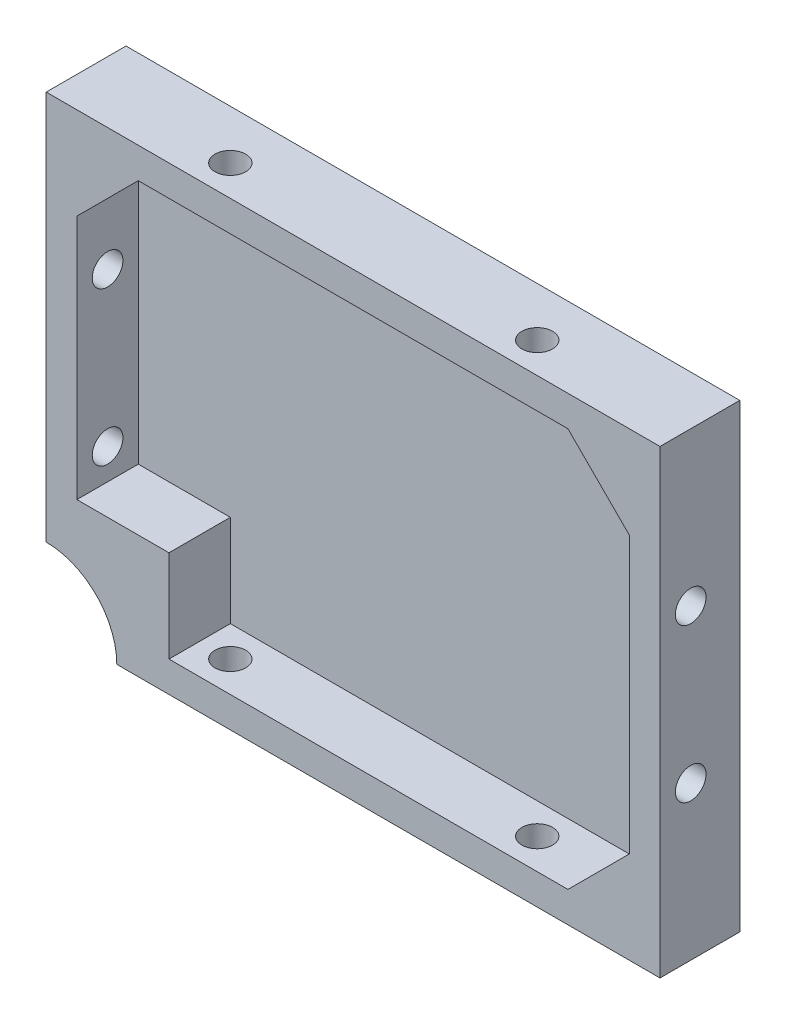
from build123d import *

# Parameters (mm, degrees)
BOSS_EXTRU_1_DEPTH        = 13
COQUE1_T                  = -5
COQUE1_THICKNESS_2_FACE_W = 90
COQUE1_THICKNESS_2_FACE_H = 65
COQUE1_THICKNESS_2_DEPTH  = 2
ENL_V_MAT_EXTRU_1_REACH   = 110.96
ESQUISSE2_R               = 2.5
ENL_V_MAT_EXTRU_2_REACH   = 95.396
ESQUISSE3_R               = 2.5
ESQUISSE4_W               = 15
ESQUISSE4_H               = 15
BOSS_EXTRU_2_DEPTH        = 10
ESQUISSE6_R               = 11.5
ENL_V_MAT_EXTRU_4_DEPTH   = 13


with BuildPart() as part:
    # Esquisse1 → Boss.-Extru.1 (new body)
    with BuildSketch(Plane.XY):
        Polygon((44.118436308, 33.728448276), (54.118436308, 33.728448276), (54.118436308, 23.728448276), (54.118436308, -41.271551724), (-45.881563692, -41.271551724), (-45.881563692, 33.728448276), align=None)
    extrude(amount=BOSS_EXTRU_1_DEPTH)

    # Coque1
    coque1_openings = [part.faces().sort_by_distance(p)[0] for p in [
        (4.118436308, -3.771551724, 13),
    ]]
    offset(amount=COQUE1_T, openings=coque1_openings, kind=Kind.INTERSECTION)

    # Coque1 thickness 2 face (on inner face of the shell) → Coque1 thickness 2 (cut)
    with BuildSketch(Plane(origin=(4.118436308, -3.771551724, 5), x_dir=(-1, 0, 0), z_dir=(0, 0, -1))):
        Rectangle(COQUE1_THICKNESS_2_FACE_W, COQUE1_THICKNESS_2_FACE_H)
    extrude(amount=COQUE1_THICKNESS_2_DEPTH, mode=Mode.SUBTRACT)

    # Enlèv. mat.-Extru.1: up to this face of the body (flat: up to its plane)
    enl_v_mat_extru_1_end = Plane(part.part.faces().sort_by_distance((54.118436308, -3.771551724, 6.5))[0])
    # Esquisse2 → Enlèv. mat.-Extru.1 (cut, up to the picked face)
    with BuildSketch(Plane.ZY.offset(45.881563692), mode=Mode.PRIVATE) as enl_v_mat_extru_1_sk1:
        with Locations(Location((8, -16.271551724, 0), (0, 0, 270))):
            Circle(ESQUISSE2_R)
    enl_v_mat_extru_1_tool1 = split(extrude(enl_v_mat_extru_1_sk1.sketch, amount=-ENL_V_MAT_EXTRU_1_REACH, mode=Mode.PRIVATE), bisect_by=enl_v_mat_extru_1_end, keep=Keep.BOTH, mode=Mode.PRIVATE)
    # Esquisse2 → Enlèv. mat.-Extru.1 (cut, up to the picked face)
    with BuildSketch(Plane.ZY.offset(45.881563692), mode=Mode.PRIVATE) as enl_v_mat_extru_1_sk2:
        with Locations(Location((8, 8.728448276, 0), (0, 0, 270))):
            Circle(ESQUISSE2_R)
    enl_v_mat_extru_1_tool2 = split(extrude(enl_v_mat_extru_1_sk2.sketch, amount=-ENL_V_MAT_EXTRU_1_REACH, mode=Mode.PRIVATE), bisect_by=enl_v_mat_extru_1_end, keep=Keep.BOTH, mode=Mode.PRIVATE)
    add(enl_v_mat_extru_1_tool1.solids().sort_by(Axis((-45.881564, -16.271552, 8), (1, 0, 0)))[0], mode=Mode.SUBTRACT)
    add(enl_v_mat_extru_1_tool2.solids().sort_by(Axis((-45.881564, 8.728448, 8), (1, 0, 0)))[0], mode=Mode.SUBTRACT)

    # Enlèv. mat.-Extru.2: up to this face of the body (flat: up to its plane)
    enl_v_mat_extru_2_end = Plane(part.part.faces().sort_by_distance((4.118436308, 33.728448276, 6.5))[0])
    # Esquisse3 → Enlèv. mat.-Extru.2 (cut, up to the picked face)
    with BuildSketch(Plane.XZ.offset(41.271551724), mode=Mode.PRIVATE) as enl_v_mat_extru_2_sk1:
        with Locations(Location((-20.881563692, 8, 0), (0, 0, 270))):
            Circle(ESQUISSE3_R)
    enl_v_mat_extru_2_tool1 = split(extrude(enl_v_mat_extru_2_sk1.sketch, amount=-ENL_V_MAT_EXTRU_2_REACH, mode=Mode.PRIVATE), bisect_by=enl_v_mat_extru_2_end, keep=Keep.BOTH, mode=Mode.PRIVATE)
    # Esquisse3 → Enlèv. mat.-Extru.2 (cut, up to the picked face)
    with BuildSketch(Plane.XZ.offset(41.271551724), mode=Mode.PRIVATE) as enl_v_mat_extru_2_sk2:
        with Locations(Location((29.118436308, 8, 0), (0, 0, 270))):
            Circle(ESQUISSE3_R)
    enl_v_mat_extru_2_tool2 = split(extrude(enl_v_mat_extru_2_sk2.sketch, amount=-ENL_V_MAT_EXTRU_2_REACH, mode=Mode.PRIVATE), bisect_by=enl_v_mat_extru_2_end, keep=Keep.BOTH, mode=Mode.PRIVATE)
    add(enl_v_mat_extru_2_tool1.solids().sort_by(Axis((-20.881564, -41.271552, 8), (0, 1, 0)))[0], mode=Mode.SUBTRACT)
    add(enl_v_mat_extru_2_tool2.solids().sort_by(Axis((29.118436, -41.271552, 8), (0, 1, 0)))[0], mode=Mode.SUBTRACT)

    # Esquisse4 → Boss.-Extru.2 (add)
    with BuildSketch(Plane.XY.offset(3)):
        Polygon((-30.881563692, 28.728448276), (-40.881563692, 18.728448276), (-40.881563692, 28.728448276), align=None)
        Polygon((49.118436308, 28.728448276), (49.118436308, 18.728448276), (39.118436308, 28.728448276), align=None)
        Polygon((49.118436308, -36.271551724), (49.118436308, -26.271551724), (39.118436308, -36.271551724), align=None)
        with Locations((-33.381563692, -28.771551724)):
            Rectangle(ESQUISSE4_W, ESQUISSE4_H)
    extrude(amount=BOSS_EXTRU_2_DEPTH)

    # Esquisse6 → Enlèv. mat.-Extru.4 (cut)
    with BuildSketch(Plane.XY.offset(13)):
        with Locations((-45.881563692, -41.271551724)):
            Circle(ESQUISSE6_R)
    extrude(amount=-ENL_V_MAT_EXTRU_4_DEPTH, mode=Mode.SUBTRACT)


solid = part.part
